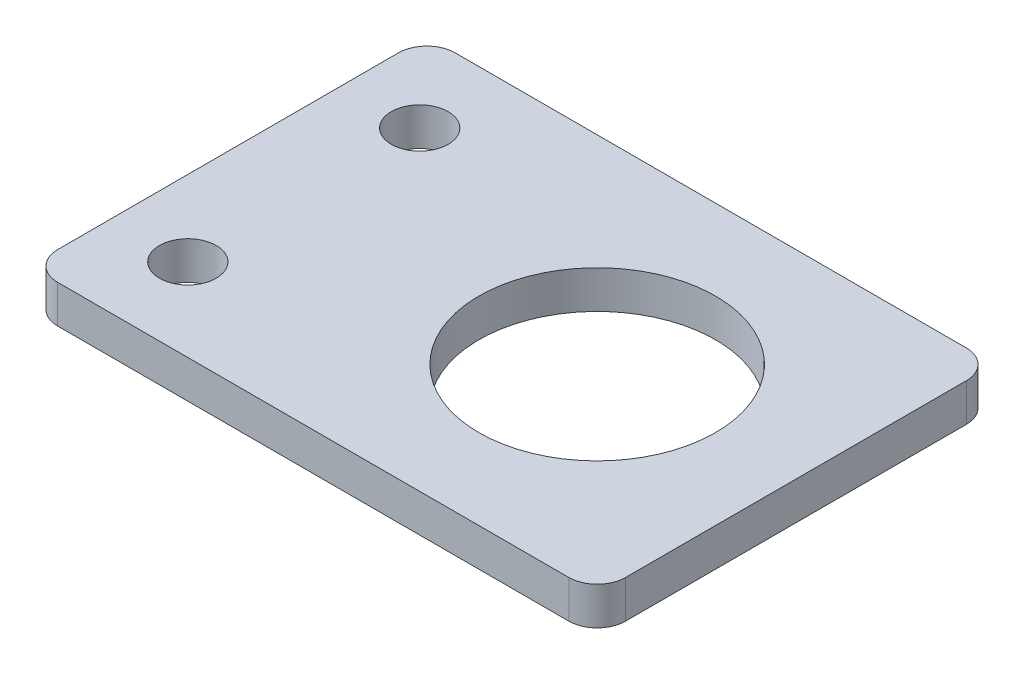
from build123d import *

# Parameters (mm, degrees)
SKETCH1_W           = 60
SKETCH1_H           = 42
SKETCH1_R           = 12.5
SKETCH1_R_2         = 3
BOSS_EXTRUDE1_DEPTH = 4
FILLET2_R           = 3


with BuildPart() as part:
    # Sketch1 → Boss-Extrude1 (new body)
    with BuildSketch(Plane(origin=(0, 0, 0), x_dir=(1, 0, 0), z_dir=(0, 1, 0))):
        Rectangle(SKETCH1_W, SKETCH1_H)
        with Locations((9, 0)):
            Circle(SKETCH1_R, mode=Mode.SUBTRACT)
        with Locations((-22, 12.25)):
            Circle(SKETCH1_R_2, mode=Mode.SUBTRACT)
        with Locations((-22, -12.25)):
            Circle(SKETCH1_R_2, mode=Mode.SUBTRACT)
    extrude(amount=BOSS_EXTRUDE1_DEPTH)

    # Fillet2
    fillet2_edges = [part.edges().sort_by_distance(p)[0] for p in [
        (30, 2, 21),
        (-30, 2, 21),
        (-30, 2, -21),
        (30, 2, -21),
    ]]
    fillet(fillet2_edges, radius=FILLET2_R)


solid = part.part
